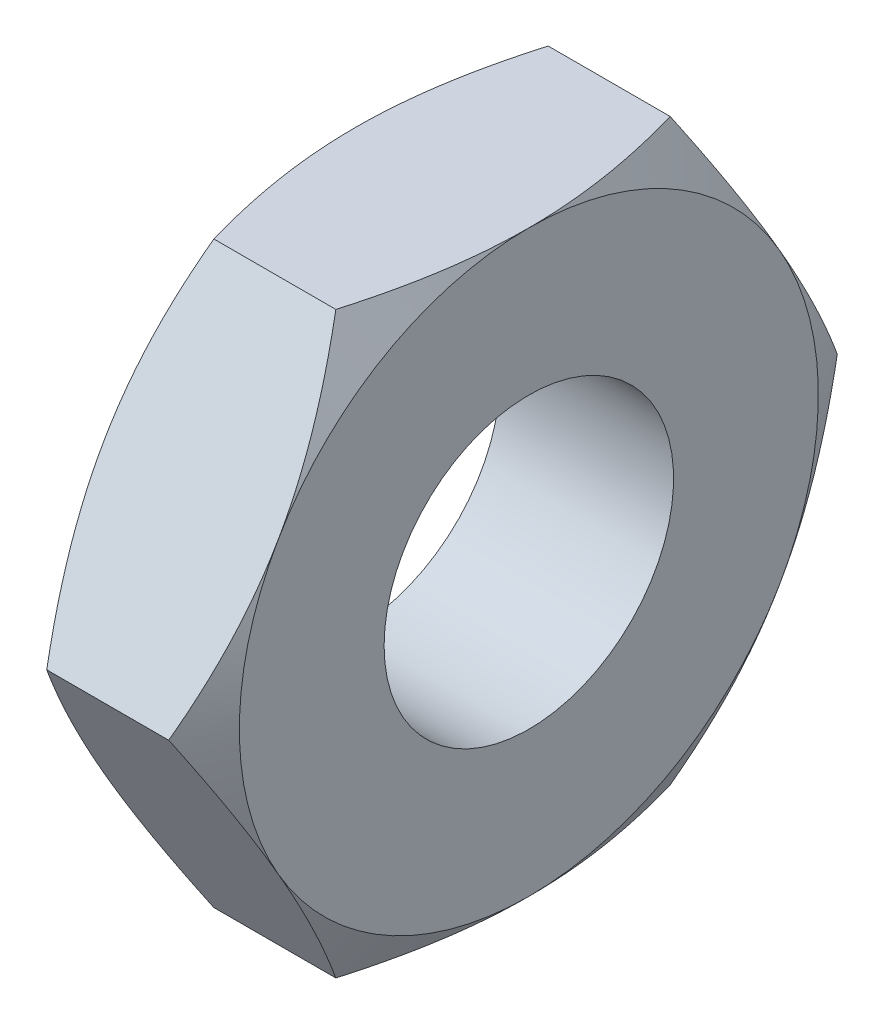
from build123d import *

# Parameters (mm, degrees)
BOSS_EXTRUDE1_DEPTH = 3
TAPPED_HOLE1_D      = 5


with BuildPart() as part:
    # Sketch1 → Boss-Extrude1 (new body)
    with BuildSketch(Plane(origin=(0, 0, 0), x_dir=(0, 0, -1), z_dir=(1, 0, 0))):
        Polygon((5.773502692, 0), (2.886751346, 5), (-2.886751346, 5), (-5.773502692, 0), (-2.886751346, -5), (2.886751346, -5), align=None)
    extrude(amount=BOSS_EXTRUDE1_DEPTH)

    # Tapped Hole1 (through all)
    with Locations(Plane.ZY):
        with Locations((0, 0)):
            Hole(TAPPED_HOLE1_D / 2)

    # Sketch6 → Cut-Revolve1 (revolve, cut)
    with BuildSketch(Plane(origin=(0, 0, 0), x_dir=(1, 0, 0), z_dir=(0, 1, 0))):
        Polygon((0, 5), (0.446581987, 5.773502692), (0, 5.773502692), align=None)
    cut_revolve1 = revolve(axis=Axis((0, 0, 0), (1, 0, 0)), mode=Mode.SUBTRACT)

    # Mirror1: Cut-Revolve1 across plane
    add(cut_revolve1.mirror(Plane.ZY.offset(-1.5)), mode=Mode.SUBTRACT)


solid = part.part
